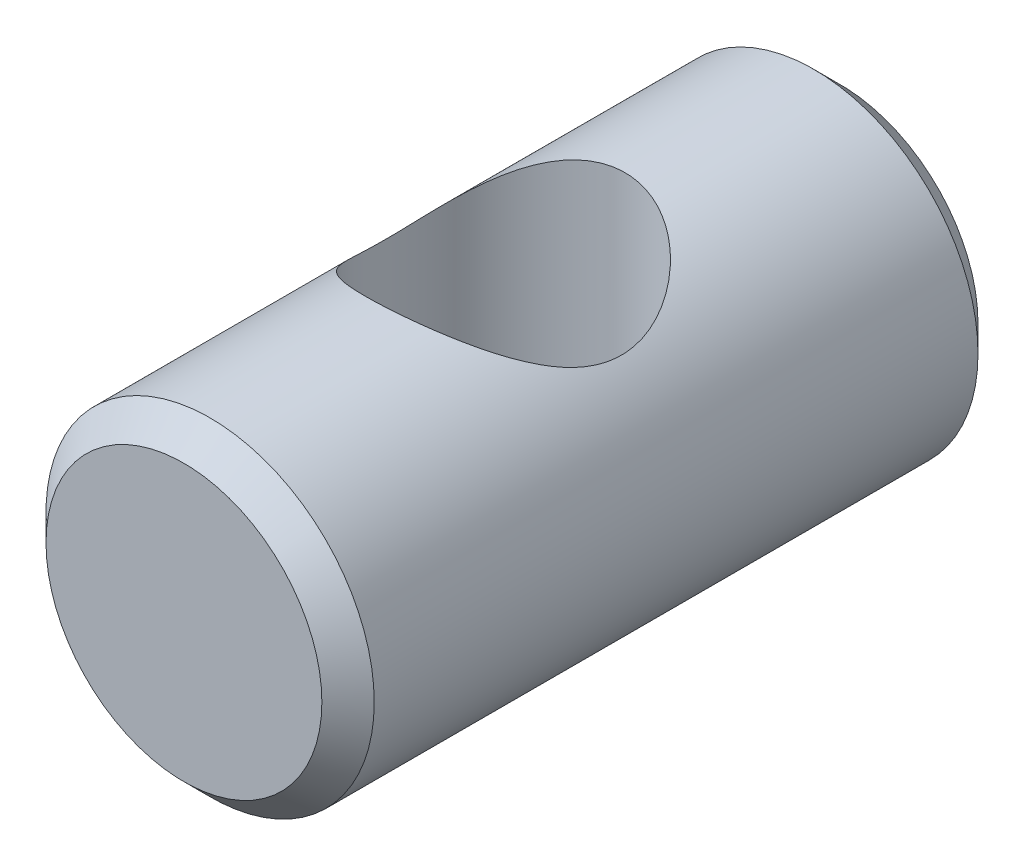
from build123d import *

# Parameters (mm, degrees)
SKETCH1_R               = 4.765
BOSS_EXTRUDE1_DEPTH     = 9.525
CHAMFER1_SIZE           = 0.76
SKETCH2_R               = 3.43
CUT_EXTRUDE1_DEPTH      = 5.765
CUT_EXTRUDE1_DEPTH_BACK = 5.765


with BuildPart() as part:
    # Sketch1 → Boss-Extrude1 (new body, symmetric)
    with BuildSketch(Plane.XY):
        Circle(SKETCH1_R)
    extrude(amount=BOSS_EXTRUDE1_DEPTH, both=True)

    # Chamfer1
    chamfer1_edges = [part.edges().sort_by_distance(p)[0] for p in [
        (-4.765, 0, -9.525),
        (-4.765, 0, 9.525),
    ]]
    chamfer(chamfer1_edges, length=CHAMFER1_SIZE)

    # Sketch2 → Cut-Extrude1 (cut, two sides)
    with BuildSketch(Plane(origin=(0, 0, 0), x_dir=(1, 0, 0), z_dir=(0, 1, 0))) as cut_extrude1_sk:
        with Locations((-0.25, 0)):
            Circle(SKETCH2_R)
    extrude(amount=CUT_EXTRUDE1_DEPTH, mode=Mode.SUBTRACT)
    extrude(cut_extrude1_sk.sketch, amount=-CUT_EXTRUDE1_DEPTH_BACK, mode=Mode.SUBTRACT)


solid = part.part
